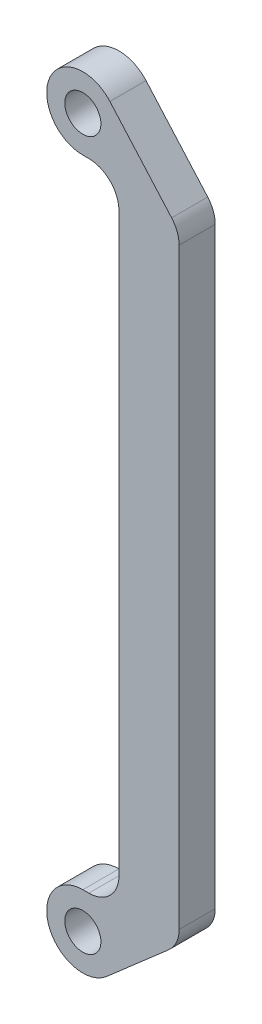
from build123d import *

# Parameters (mm, degrees)
CROQUIS1_R              = 3
CROQUIS1_R_2            = 6
SALIENTE_EXTRUIR1_DEPTH = 6


with BuildPart() as part:
    # Croquis1 → Saliente-Extruir1 (new body)
    with BuildSketch(Plane.XY):
        with BuildLine():
            ThreePointArc((0, -6), (2.10674065, -5.617975065), (3.945205479, -4.520547945))
            ThreePointArc((3.945205479, -4.520547945), (5.462198865, -2.482817666), (6, 0))
            ThreePointArc((6, 0), (4.242640687, 4.242640687), (0, 6))
            ThreePointArc((0, 6), (-4.242640687, 4.242640687), (-6, 0))
            ThreePointArc((-6, 0), (-4.242640687, -4.242640687), (0, -6))
        make_face()
        Circle(CROQUIS1_R, mode=Mode.SUBTRACT)
        with BuildLine():
            ThreePointArc((14.287671233, 4.505603985), (15.551832387, 6.203712551), (16, 8.272727273))
            Line((16, 8.272727273), (16, 106.727272727))
            ThreePointArc((16, 106.727272727), (15.677138032, 108.494864262), (14.750248066, 110.034180564))
            Line((14.750248066, 110.034180564), (4.50029768, 121.658289404))
            ThreePointArc((4.50029768, 121.658289404), (5.612565638, 119.811109842), (6, 117.69))
            ThreePointArc((6, 117.69), (4.242640687, 113.447359313), (0, 111.69))
            Line((0, 111.69), (1, 111.69))
            ThreePointArc((1, 111.69), (4.535533906, 110.225533906), (6, 106.69))
            Line((6, 106.69), (6, 11))
            ThreePointArc((6, 11), (4.535533906, 7.464466094), (1, 6))
            Line((1, 6), (0, 6))
            ThreePointArc((0, 6), (4.242640687, 4.242640687), (6, 0))
            ThreePointArc((6, 0), (5.462198865, -2.482817666), (3.945205479, -4.520547945))
            Line((3.945205479, -4.520547945), (14.287671233, 4.505603985))
        make_face()
        with Locations((0, 117.69)):
            Circle(CROQUIS1_R_2)
        with Locations((0, 117.69)):
            Circle(CROQUIS1_R, mode=Mode.SUBTRACT)
    extrude(amount=SALIENTE_EXTRUIR1_DEPTH)


solid = part.part
